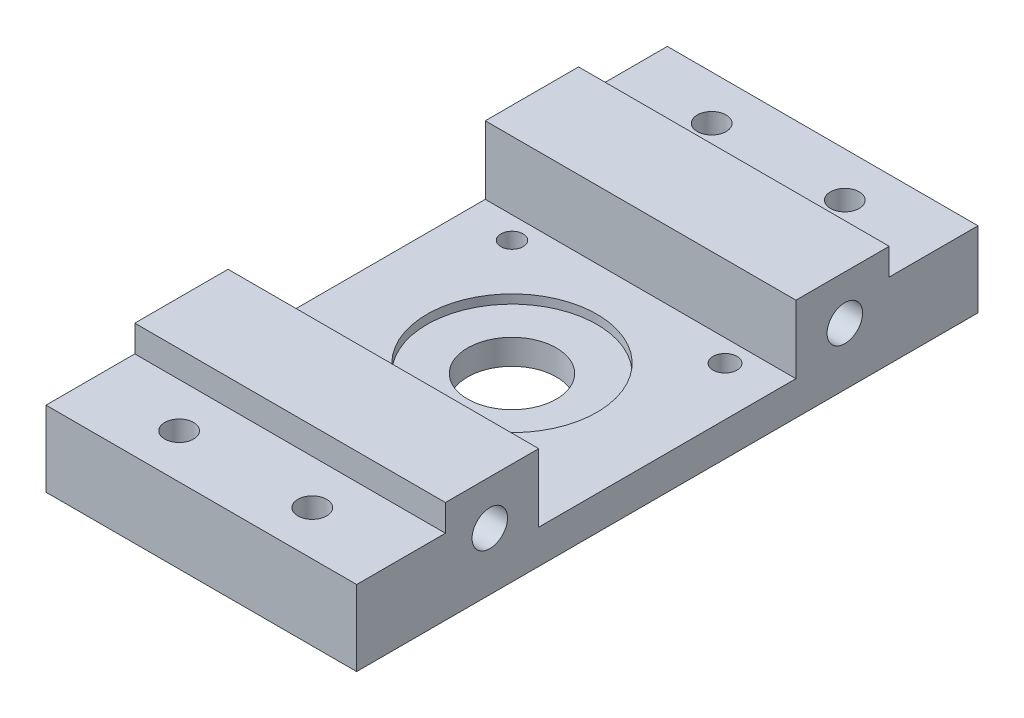
from build123d import *

# Parameters (mm, degrees)
BOSS_EXTRUDE1_DEPTH = 70
CUT_EXTRUDE1_REACH  = 72
SKETCH14_R          = 4
CUT_EXTRUDE2_REACH  = 19
SKETCH15_R          = 3.25
CUT_EXTRUDE3_REACH  = 72
SKETCH16_W          = 57.95105002
SKETCH16_H          = 16.678137539
SKETCH17_R          = 19.15
CUT_EXTRUDE4_DEPTH  = 2
CUT_EXTRUDE5_REACH  = 7.672
SKETCH18_R          = 10
CUT_EXTRUDE6_REACH  = 9.672
SKETCH19_R          = 2.5
SKETCH19_R_2        = 2.7
SKETCH19_R_3        = 2.618497629


with BuildPart() as part:
    # Sketch12 → Boss-Extrude1 (new body)
    with BuildSketch(Plane(origin=(0, 0, 0), x_dir=(0, 0, -1), z_dir=(1, 0, 0))):
        Polygon((70.005446089, -2.999997853), (-70, -2.999997853), (-70, 14.000002147), (-50, 14.000002147), (-50, 20.000002147), (50, 20.000002147), (50, 14.000002147), (70.005446089, 14.000002147), align=None)
    extrude(amount=BOSS_EXTRUDE1_DEPTH)

    # Sketch14 → Cut-Extrude1 (cut, up to next)
    with BuildSketch(Plane.ZY, mode=Mode.PRIVATE) as cut_extrude1_sk1:
        with Locations((-40, 10.000001073)):
            Circle(SKETCH14_R)
    cut_extrude1_tool1 = extrude(cut_extrude1_sk1.sketch, amount=-CUT_EXTRUDE1_REACH, mode=Mode.PRIVATE) & part.part
    add(cut_extrude1_tool1.solids().sort_by_distance((0, 10.000001, -40))[0], mode=Mode.SUBTRACT)
    # Sketch14 → Cut-Extrude1 (cut, up to next)
    with BuildSketch(Plane.ZY, mode=Mode.PRIVATE) as cut_extrude1_sk2:
        with Locations((40, 10.000001073)):
            Circle(SKETCH14_R)
    cut_extrude1_tool2 = extrude(cut_extrude1_sk2.sketch, amount=-CUT_EXTRUDE1_REACH, mode=Mode.PRIVATE) & part.part
    add(cut_extrude1_tool2.solids().sort_by_distance((0, 10.000001, 40))[0], mode=Mode.SUBTRACT)

    # Sketch15 → Cut-Extrude2 (cut, up to next)
    with BuildSketch(Plane(origin=(0, 14.000002147, 0), x_dir=(1, 0, 0), z_dir=(0, 1, 0)), mode=Mode.PRIVATE) as cut_extrude2_sk1:
        with Locations((50, 60.002723044)):
            Circle(SKETCH15_R)
    cut_extrude2_tool1 = extrude(cut_extrude2_sk1.sketch, amount=-CUT_EXTRUDE2_REACH, mode=Mode.PRIVATE) & part.part
    add(cut_extrude2_tool1.solids().sort_by_distance((50, 14.000002, -60.002723))[0], mode=Mode.SUBTRACT)
    # Sketch15 → Cut-Extrude2 (cut, up to next)
    with BuildSketch(Plane(origin=(0, 14.000002147, 0), x_dir=(1, 0, 0), z_dir=(0, 1, 0)), mode=Mode.PRIVATE) as cut_extrude2_sk2:
        with Locations((20, 60.002723044)):
            Circle(SKETCH15_R)
    cut_extrude2_tool2 = extrude(cut_extrude2_sk2.sketch, amount=-CUT_EXTRUDE2_REACH, mode=Mode.PRIVATE) & part.part
    add(cut_extrude2_tool2.solids().sort_by_distance((20, 14.000002, -60.002723))[0], mode=Mode.SUBTRACT)
    # Sketch15 → Cut-Extrude2 (cut, up to next)
    with BuildSketch(Plane(origin=(0, 14.000002147, 0), x_dir=(1, 0, 0), z_dir=(0, 1, 0)), mode=Mode.PRIVATE) as cut_extrude2_sk3:
        with Locations((50, -60)):
            Circle(SKETCH15_R)
    cut_extrude2_tool3 = extrude(cut_extrude2_sk3.sketch, amount=-CUT_EXTRUDE2_REACH, mode=Mode.PRIVATE) & part.part
    add(cut_extrude2_tool3.solids().sort_by_distance((50, 14.000002, 60))[0], mode=Mode.SUBTRACT)
    # Sketch15 → Cut-Extrude2 (cut, up to next)
    with BuildSketch(Plane(origin=(0, 14.000002147, 0), x_dir=(1, 0, 0), z_dir=(0, 1, 0)), mode=Mode.PRIVATE) as cut_extrude2_sk4:
        with Locations((20, -60)):
            Circle(SKETCH15_R)
    cut_extrude2_tool4 = extrude(cut_extrude2_sk4.sketch, amount=-CUT_EXTRUDE2_REACH, mode=Mode.PRIVATE) & part.part
    add(cut_extrude2_tool4.solids().sort_by_distance((20, 14.000002, 60))[0], mode=Mode.SUBTRACT)

    # Sketch16 → Cut-Extrude3 (cut, up to next)
    with BuildSketch(Plane.ZY, mode=Mode.PRIVATE) as cut_extrude3_sk1:
        with Locations((0, 13.011297134)):
            Rectangle(SKETCH16_W, SKETCH16_H)
    cut_extrude3_tool1 = extrude(cut_extrude3_sk1.sketch, amount=-CUT_EXTRUDE3_REACH, mode=Mode.PRIVATE) & part.part
    add(cut_extrude3_tool1.solids().sort_by_distance((0, 13.011297, 0))[0], mode=Mode.SUBTRACT)

    # Sketch17 → Cut-Extrude4 (cut)
    with BuildSketch(Plane(origin=(0, 4.672228364, 0), x_dir=(1, 0, 0), z_dir=(0, 1, 0))):
        with Locations((35, 0)):
            Circle(SKETCH17_R)
    extrude(amount=-CUT_EXTRUDE4_DEPTH, mode=Mode.SUBTRACT)

    # Sketch18 → Cut-Extrude5 (cut, up to next)
    with BuildSketch(Plane(origin=(0, 2.672228364, 0), x_dir=(1, 0, 0), z_dir=(0, 1, 0)), mode=Mode.PRIVATE) as cut_extrude5_sk1:
        with Locations((35, 0)):
            Circle(SKETCH18_R)
    cut_extrude5_tool1 = extrude(cut_extrude5_sk1.sketch, amount=-CUT_EXTRUDE5_REACH, mode=Mode.PRIVATE) & part.part
    add(cut_extrude5_tool1.solids().sort_by_distance((35, 2.672228, 0))[0], mode=Mode.SUBTRACT)

    # Sketch19 → Cut-Extrude6 (cut, up to next)
    with BuildSketch(Plane(origin=(0, 4.672228364, 0), x_dir=(1, 0, 0), z_dir=(0, 1, 0)), mode=Mode.PRIVATE) as cut_extrude6_sk1:
        with Locations((11, 24)):
            Circle(SKETCH19_R)
    cut_extrude6_tool1 = extrude(cut_extrude6_sk1.sketch, amount=-CUT_EXTRUDE6_REACH, mode=Mode.PRIVATE) & part.part
    add(cut_extrude6_tool1.solids().sort_by_distance((11, 4.672228, -24))[0], mode=Mode.SUBTRACT)
    # Sketch19 → Cut-Extrude6 (cut, up to next)
    with BuildSketch(Plane(origin=(0, 4.672228364, 0), x_dir=(1, 0, 0), z_dir=(0, 1, 0)), mode=Mode.PRIVATE) as cut_extrude6_sk2:
        with Locations((59, 24)):
            Circle(SKETCH19_R_2)
    cut_extrude6_tool2 = extrude(cut_extrude6_sk2.sketch, amount=-CUT_EXTRUDE6_REACH, mode=Mode.PRIVATE) & part.part
    add(cut_extrude6_tool2.solids().sort_by_distance((59, 4.672228, -24))[0], mode=Mode.SUBTRACT)
    # Sketch19 → Cut-Extrude6 (cut, up to next)
    with BuildSketch(Plane(origin=(0, 4.672228364, 0), x_dir=(1, 0, 0), z_dir=(0, 1, 0)), mode=Mode.PRIVATE) as cut_extrude6_sk3:
        with Locations((59, -24)):
            Circle(SKETCH19_R_3)
    cut_extrude6_tool3 = extrude(cut_extrude6_sk3.sketch, amount=-CUT_EXTRUDE6_REACH, mode=Mode.PRIVATE) & part.part
    add(cut_extrude6_tool3.solids().sort_by_distance((59, 4.672228, 24))[0], mode=Mode.SUBTRACT)
    # Sketch19 → Cut-Extrude6 (cut, up to next)
    with BuildSketch(Plane(origin=(0, 4.672228364, 0), x_dir=(1, 0, 0), z_dir=(0, 1, 0)), mode=Mode.PRIVATE) as cut_extrude6_sk4:
        with Locations((11, -24)):
            Circle(SKETCH19_R_2)
    cut_extrude6_tool4 = extrude(cut_extrude6_sk4.sketch, amount=-CUT_EXTRUDE6_REACH, mode=Mode.PRIVATE) & part.part
    add(cut_extrude6_tool4.solids().sort_by_distance((11, 4.672228, 24))[0], mode=Mode.SUBTRACT)


solid = part.part
